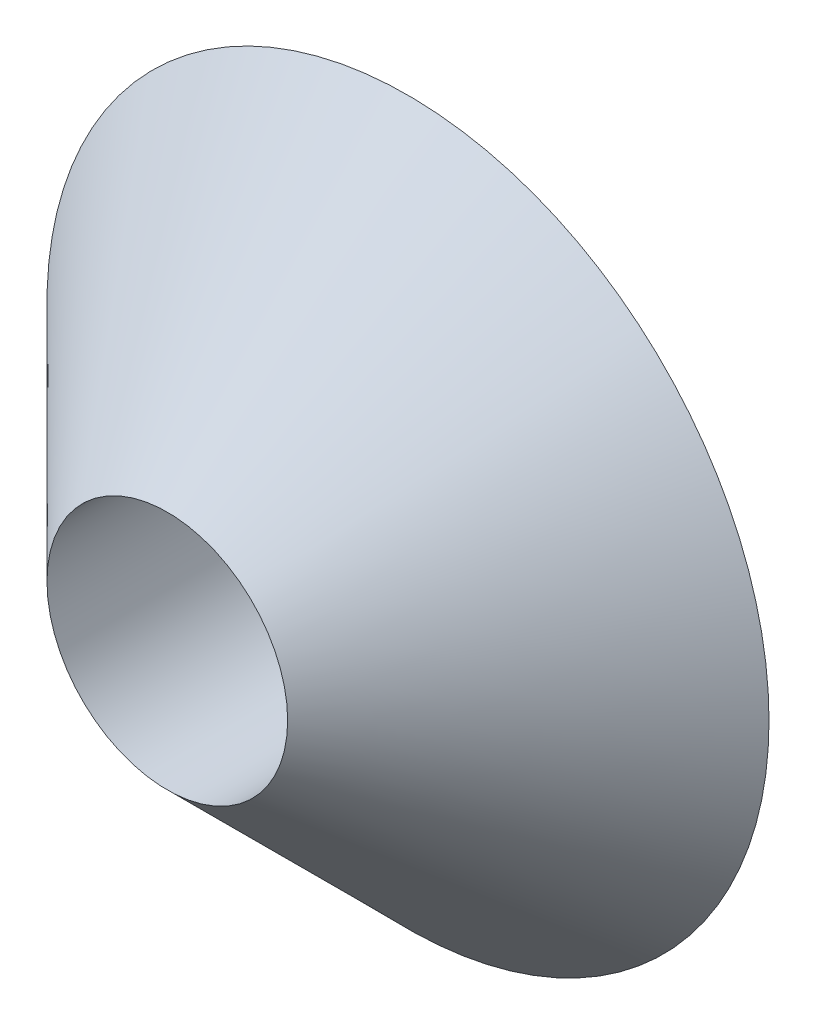
from build123d import *

# Parameters (mm, degrees)
SKETCH14_R         = 5
CUT_EXTRUDE1_DEPTH = 11


with BuildPart() as part:
    # Sketch1 → Revolve1 (revolve)
    with BuildSketch(Plane(origin=(0, 0, 0), x_dir=(1, 0, 0), z_dir=(0, 1, 0))):
        Polygon((0, 0), (-5, 0), (-15, 10), (0, 10), align=None)
    revolve(axis=Axis((0, 0, 0), (0, 0, -1)))

    # Sketch14 → Cut-Extrude1 (cut, through all)
    with BuildSketch(Plane.XY):
        Circle(SKETCH14_R)
    extrude(amount=-CUT_EXTRUDE1_DEPTH, mode=Mode.SUBTRACT)


solid = part.part
